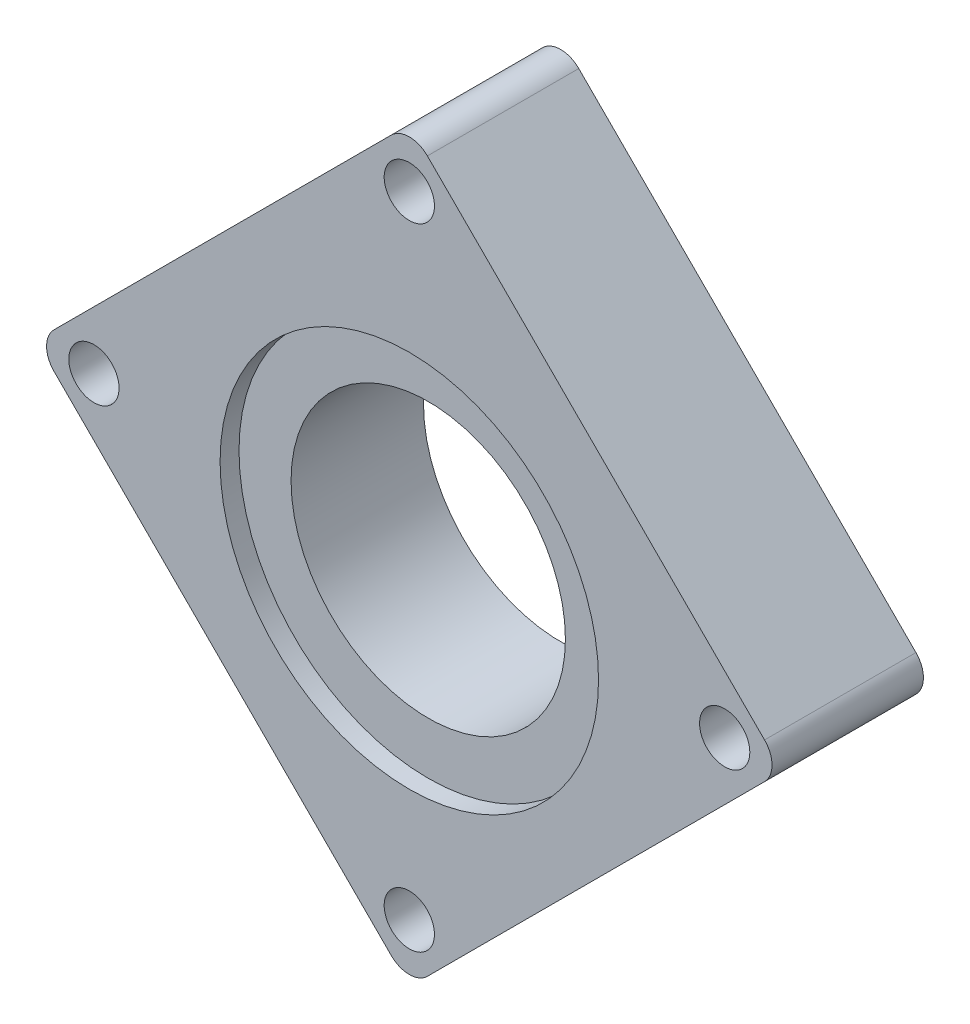
from build123d import *

# Parameters (mm, degrees)
SKETCH1_R           = 14.5
SKETCH1_R_2         = 2.655602963
BOSS_EXTRUDE1_DEPTH = 16
SKETCH2_R           = 20
CUT_EXTRUDE1_DEPTH  = 2


with BuildPart() as part:
    # Sketch1 → Boss-Extrude1 (new body)
    with BuildSketch(Plane.XY):
        with BuildLine():
            Line((96.456721684, 48.36687177), (64.849048565, 79.974544889))
            Line((64.849048565, 79.974544889), (60.818539912, 84.005053542))
            ThreePointArc((60.818539912, 84.005053542), (58.909351603, 84.795865233), (57.000163293, 84.005053542))
            Line((57.000163293, 84.005053542), (25.392490174, 52.397380423))
            Line((25.392490174, 52.397380423), (21.361981522, 48.36687177))
            ThreePointArc((21.361981522, 48.36687177), (20.571169831, 46.457683461), (21.361981522, 44.548495152))
            Line((21.361981522, 44.548495152), (52.969654641, 12.940822033))
            Line((52.969654641, 12.940822033), (57.000163293, 8.91031338))
            ThreePointArc((57.000163293, 8.91031338), (58.909351603, 8.119501689), (60.818539912, 8.91031338))
            Line((60.818539912, 8.91031338), (92.426213031, 40.517986499))
            Line((92.426213031, 40.517986499), (96.456721684, 44.548495152))
            ThreePointArc((96.456721684, 44.548495152), (97.247533374, 46.457683461), (96.456721684, 48.36687177))
        make_face()
        with Locations((58.909351603, 45.077265813)):
            Circle(SKETCH1_R, mode=Mode.SUBTRACT)
        with Locations((58.909351603, 13.124669796)):
            Circle(SKETCH1_R_2, mode=Mode.SUBTRACT)
        with Locations((92.242365268, 46.457683461)):
            Circle(SKETCH1_R_2, mode=Mode.SUBTRACT)
        with Locations((58.909351603, 79.790697126)):
            Circle(SKETCH1_R_2, mode=Mode.SUBTRACT)
        with Locations((25.576337937, 46.457683461)):
            Circle(SKETCH1_R_2, mode=Mode.SUBTRACT)
    extrude(amount=BOSS_EXTRUDE1_DEPTH)

    # Sketch2 → Cut-Extrude1 (cut)
    with BuildSketch(Plane.XY.offset(16)):
        with Locations((58.909351603, 45.077265813)):
            Circle(SKETCH2_R)
    extrude(amount=-CUT_EXTRUDE1_DEPTH, mode=Mode.SUBTRACT)


solid = part.part
